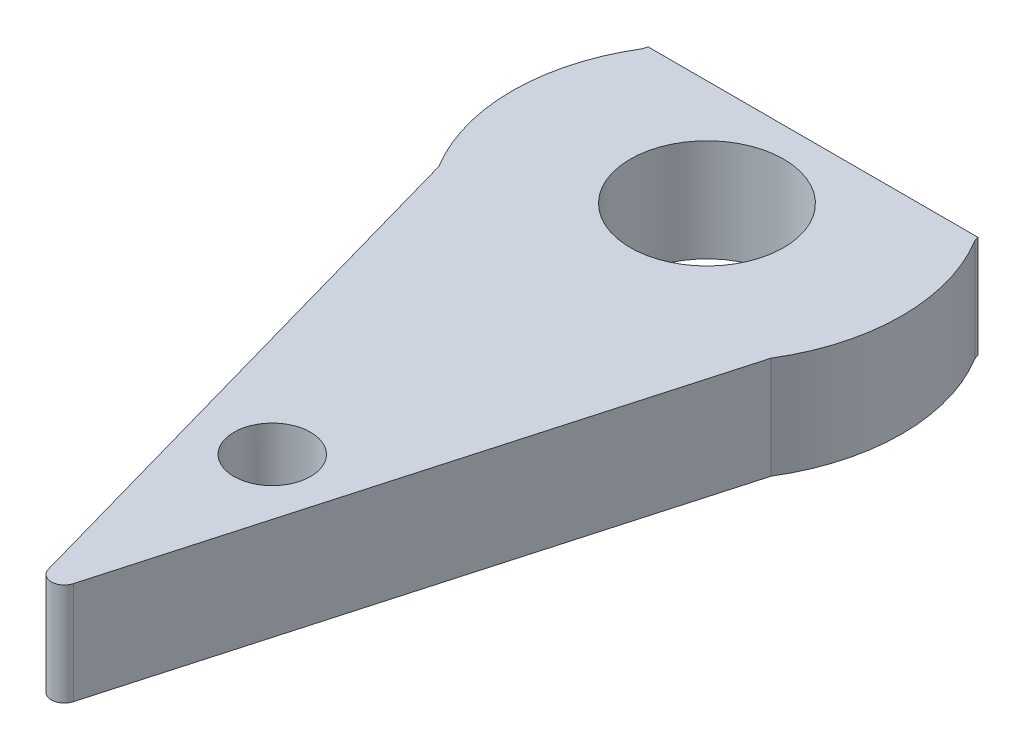
from build123d import *

# Parameters (mm, degrees)
SKETCH1_R           = 3.81
BOSS_EXTRUDE1_DEPTH = 2
BOSS_EXTRUDE2_DEPTH = 2
FILLET1_R           = 0.254
SKETCH3_R           = 0.75
CUT_EXTRUDE1_DEPTH  = 2
SKETCH4_R           = 1.5
CUT_EXTRUDE2_DEPTH  = 3
CUT_EXTRUDE3_DEPTH  = 2.54


with BuildPart() as part:
    # Sketch1 → Boss-Extrude1 (new body)
    with BuildSketch(Plane(origin=(0, 0, 0), x_dir=(1, 0, 0), z_dir=(0, 1, 0))):
        Circle(SKETCH1_R)
    extrude(amount=BOSS_EXTRUDE1_DEPTH)

    # Sketch2 → Boss-Extrude2 (add)
    with BuildSketch(Plane(origin=(0, 2, 0), x_dir=(1, 0, 0), z_dir=(0, 1, 0))):
        with BuildLine():
            Line((0, -13.5), (3.247846855, -1.991881223))
            ThreePointArc((3.247846855, -1.991881223), (0, -3.81), (-3.247846855, -1.991881223))
            Line((-3.247846855, -1.991881223), (0, -13.5))
        make_face()
        with BuildLine():
            ThreePointArc((-3.247846855, 1.991881223), (0, 3.81), (3.247846855, 1.991881223))
            Line((3.247846855, 1.991881223), (0, 13.5))
            Line((0, 13.5), (-3.247846855, 1.991881223))
        make_face()
    extrude(amount=-BOSS_EXTRUDE2_DEPTH)

    # Fillet1
    fillet1_edges = [part.edges().sort_by_distance(p)[0] for p in [
        (0, 1, -13.5),
        (0, 1, 13.5),
    ]]
    fillet(fillet1_edges, radius=FILLET1_R)

    # Sketch3 → Cut-Extrude1 (cut)
    with BuildSketch(Plane(origin=(0, 2, 0), x_dir=(1, 0, 0), z_dir=(0, 1, 0))):
        with Locations((0, 8.5)):
            Circle(SKETCH3_R)
        with Locations((0, -8.5)):
            Circle(SKETCH3_R)
    extrude(amount=-CUT_EXTRUDE1_DEPTH, mode=Mode.SUBTRACT)

    # Sketch4 → Cut-Extrude2 (cut, through all)
    with BuildSketch(Plane.XZ):
        Circle(SKETCH4_R)
    extrude(amount=-CUT_EXTRUDE2_DEPTH, mode=Mode.SUBTRACT)

    # Sketch5 → Cut-Extrude3 (cut)
    with BuildSketch(Plane(origin=(0, 0, 0), x_dir=(1, 0, 0), z_dir=(0, 1, 0))):
        Polygon((5.430650193, 2.075218265), (-5.917689048, 2.075218265), (-5.917689048, 14.831745587), (0, 14.831745587), (5.430650193, 14.831745587), align=None)
    extrude(amount=CUT_EXTRUDE3_DEPTH, mode=Mode.SUBTRACT)


solid = part.part
